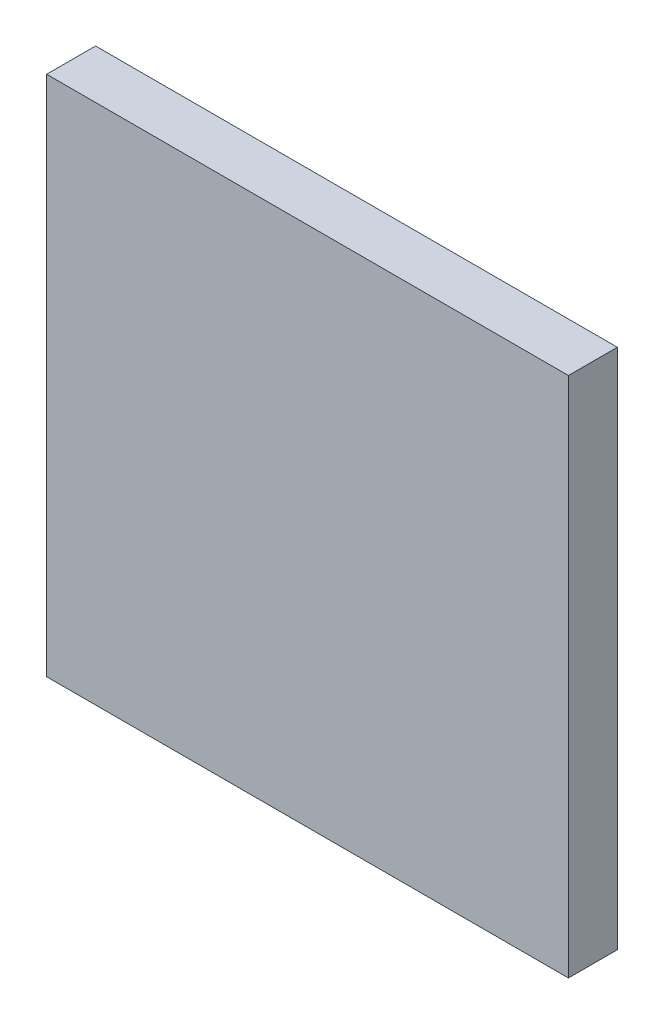
from build123d import *

# Parameters (mm, degrees)
SKETCH1_W           = 40
SKETCH1_H           = 40
BOSS_EXTRUDE1_DEPTH = 3.75


with BuildPart() as part:
    # Sketch1 → Boss-Extrude1 (new body)
    with BuildSketch(Plane.XY):
        with Locations((20, 20)):
            Rectangle(SKETCH1_W, SKETCH1_H)
    extrude(amount=BOSS_EXTRUDE1_DEPTH)


solid = part.part
